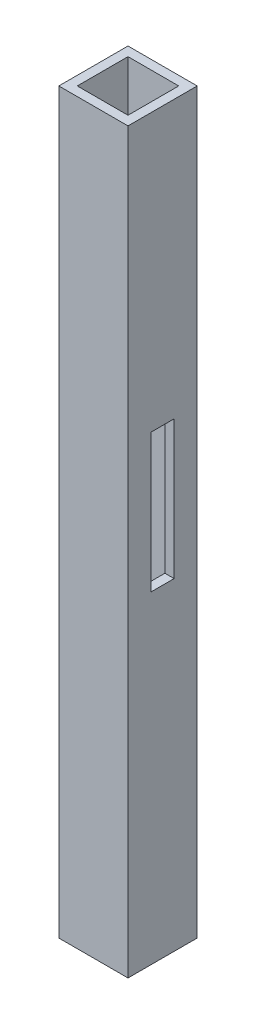
from build123d import *

# Parameters (mm, degrees)
SKETCH2_W           = 15
SKETCH2_H           = 15
SKETCH2_W_2         = 11
SKETCH2_H_2         = 11
EXTRUDE_THIN1_DEPTH = 160
SKETCH3_W           = 5
SKETCH3_H           = 30
CUT_EXTRUDE1_DEPTH  = 162.400123916


with BuildPart() as part:
    # Sketch2 → Extrude-Thin1 (new body)
    with BuildSketch(Plane(origin=(0, 0, 0), x_dir=(1, 0, 0), z_dir=(0, 1, 0))):
        with Locations((7.5, 7.5)):
            Rectangle(SKETCH2_W, SKETCH2_H)
        with Locations((7.5, 7.5)):
            Rectangle(SKETCH2_W_2, SKETCH2_H_2, mode=Mode.SUBTRACT)
    extrude(amount=EXTRUDE_THIN1_DEPTH)

    # Sketch3 → Cut-Extrude1 (cut, through all)
    with BuildSketch(Plane(origin=(15, 0, 0), x_dir=(0, 0, -1), z_dir=(1, 0, 0))):
        with Locations((7.5, 85)):
            Rectangle(SKETCH3_W, SKETCH3_H)
    extrude(amount=-CUT_EXTRUDE1_DEPTH, mode=Mode.SUBTRACT)


solid = part.part
